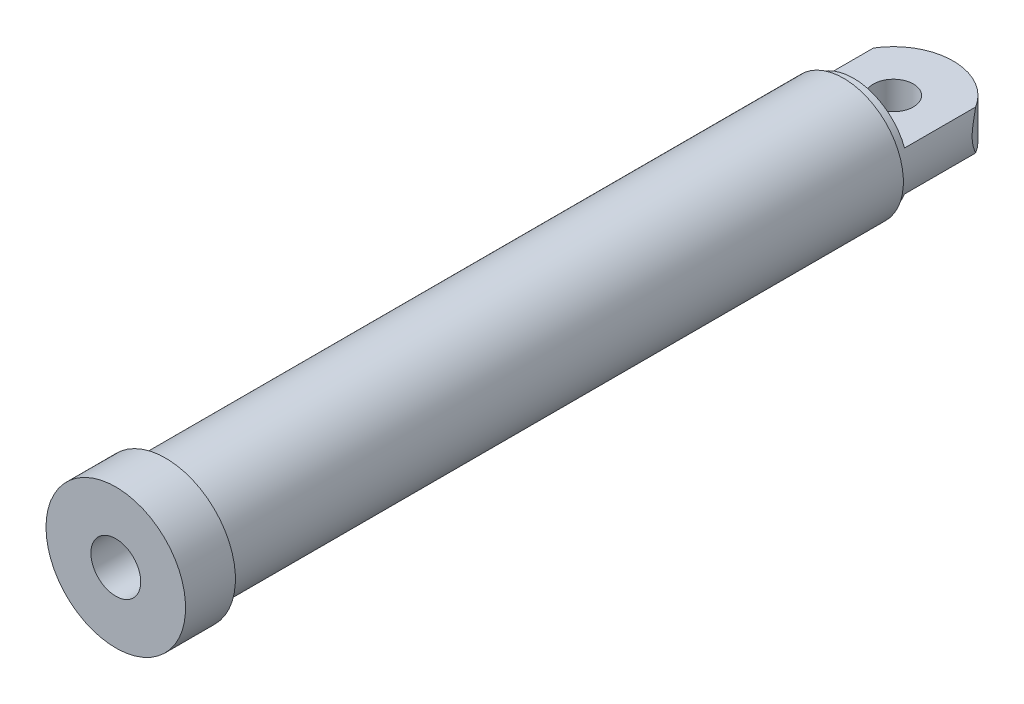
from build123d import *

# Parameters (mm, degrees)
SKETCH2_R               = 20
BOSS_EXTRUDE1_DEPTH     = 20
SKETCH3_R               = 63.245553203
SKETCH3_R_2             = 55
CUT_EXTRUDE1_DEPTH      = 101
CUT_EXTRUDE1_DEPTH_BACK = 10


with BuildPart() as part:
    # Sketch1 → Revolve1 (revolve)
    with BuildSketch(Plane(origin=(0, 0, 0), x_dir=(1, 0, 0), z_dir=(0, 1, 0))):
        Polygon((70, -780), (70, -730), (60, -730), (60, -40), (0, -40), (0, -60), (45, -60), (45, -700), (25, -700), (25, -780), align=None)
    revolve(axis=Axis((0, 0, 0), (0, 0, 1)))

    # Sketch2 → Boss-Extrude1 (add, symmetric)
    with BuildSketch(Plane(origin=(0, 0, 0), x_dir=(1, 0, 0), z_dir=(0, 1, 0))):
        with BuildLine():
            Line((60, -40), (60, 0))
            ThreePointArc((60, 0), (0, 60), (-60, 0))
            Line((-60, 0), (-60, -40))
            Line((-60, -40), (60, -40))
        make_face()
        Circle(SKETCH2_R, mode=Mode.SUBTRACT)
    extrude(amount=BOSS_EXTRUDE1_DEPTH, both=True)

    # Sketch3 → Cut-Extrude1 (cut, two sides)
    with BuildSketch(Plane(origin=(0, 0, 40), x_dir=(-1, 0, 0), z_dir=(0, 0, -1))) as cut_extrude1_sk:
        Circle(SKETCH3_R)
        Circle(SKETCH3_R_2, mode=Mode.SUBTRACT)
    extrude(amount=CUT_EXTRUDE1_DEPTH, mode=Mode.SUBTRACT)
    extrude(cut_extrude1_sk.sketch, amount=-CUT_EXTRUDE1_DEPTH_BACK, mode=Mode.SUBTRACT)


solid = part.part
